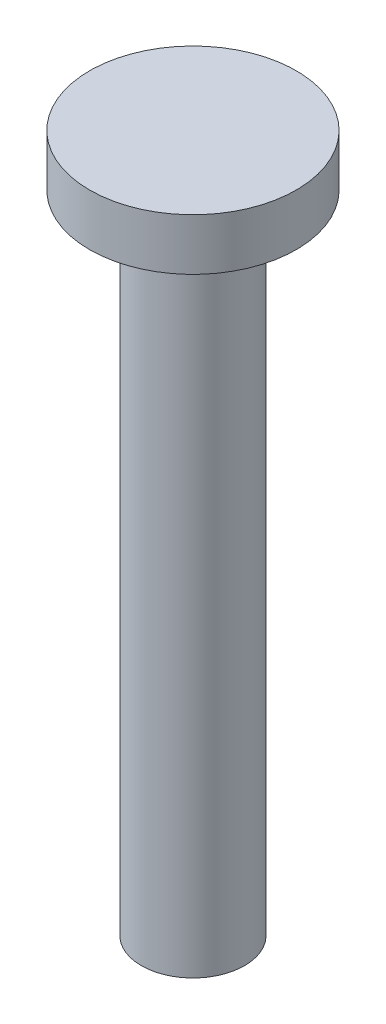
from build123d import *

# Parameters (mm, degrees)
SKETCH1_R           = 1
BOSS_EXTRUDE1_DEPTH = 12.5
SKETCH2_R           = 2
BOSS_EXTRUDE2_DEPTH = 1


with BuildPart() as part:
    # Sketch1 → Boss-Extrude1 (new body)
    with BuildSketch(Plane(origin=(0, 0, 0), x_dir=(1, 0, 0), z_dir=(0, 1, 0))):
        Circle(SKETCH1_R)
    extrude(amount=BOSS_EXTRUDE1_DEPTH)

    # Sketch2 → Boss-Extrude2 (add)
    with BuildSketch(Plane(origin=(0, 12.5, 0), x_dir=(1, 0, 0), z_dir=(0, 1, 0))):
        Circle(SKETCH2_R)
    extrude(amount=BOSS_EXTRUDE2_DEPTH)


solid = part.part
